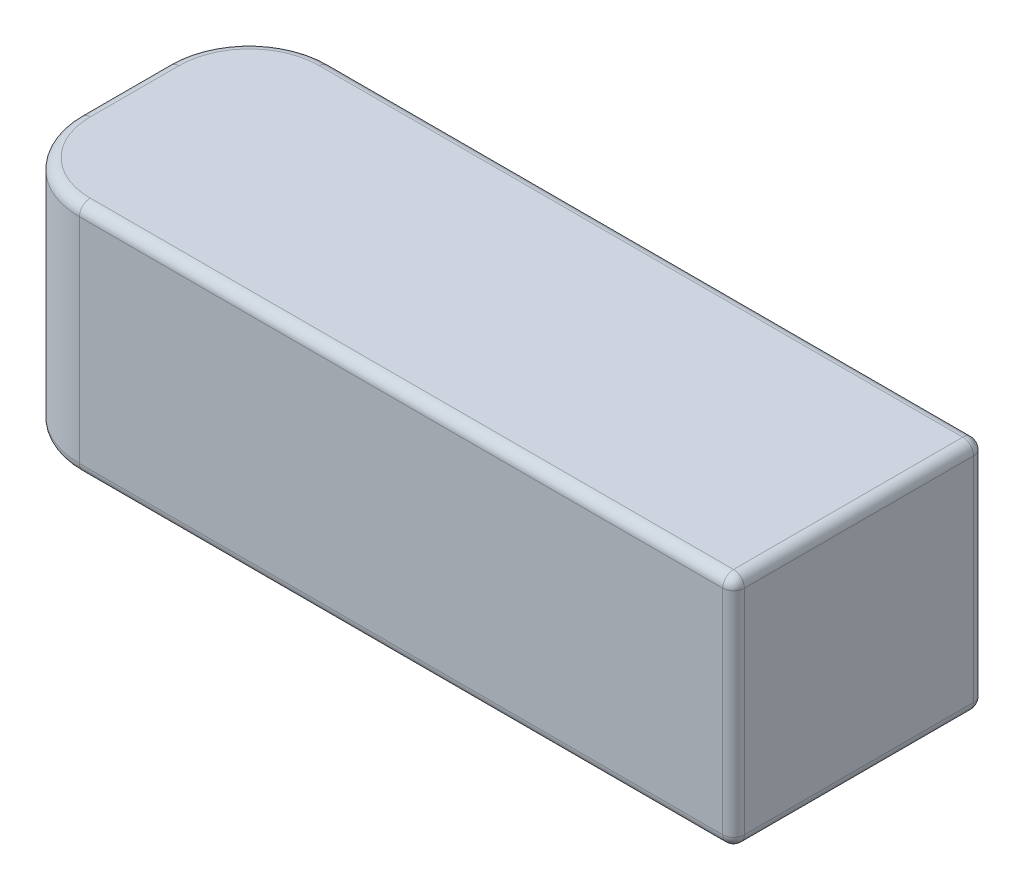
from build123d import *

# Parameters (mm, degrees)
SKETCH1_W           = 136
SKETCH1_H           = 46.4
BOSS_EXTRUDE1_DEPTH = 43.5
FILLET1_R           = 15
FILLET2_R           = 2


with BuildPart() as part:
    # Sketch1 → Boss-Extrude1 (new body)
    with BuildSketch(Plane(origin=(0, 0, 0), x_dir=(1, 0, 0), z_dir=(0, 1, 0))):
        Rectangle(SKETCH1_W, SKETCH1_H)
    extrude(amount=BOSS_EXTRUDE1_DEPTH)

    # Fillet1
    fillet1_edges = [part.edges().sort_by_distance(p)[0] for p in [
        (-68, 21.75, 23.2),
        (-68, 21.75, -23.2),
    ]]
    fillet(fillet1_edges, radius=FILLET1_R)

    # Fillet2
    fillet2_edges = [part.edges().sort_by_distance(p)[0] for p in [
        (-68, 0, 0),
        (-68, 43.5, 0),
        (7.5, 0, 23.2),
        (-63.606601718, 0, 18.806601718),
        (-63.606601718, 0, -18.806601718),
        (7.5, 43.5, 23.2),
        (-63.606601718, 43.5, 18.806601718),
        (-63.606601718, 43.5, -18.806601718),
        (68, 43.5, 0),
        (7.5, 0, -23.2),
        (68, 0, 0),
        (7.5, 43.5, -23.2),
        (68, 21.75, 23.2),
        (68, 21.75, -23.2),
    ]]
    fillet(fillet2_edges, radius=FILLET2_R)


solid = part.part
